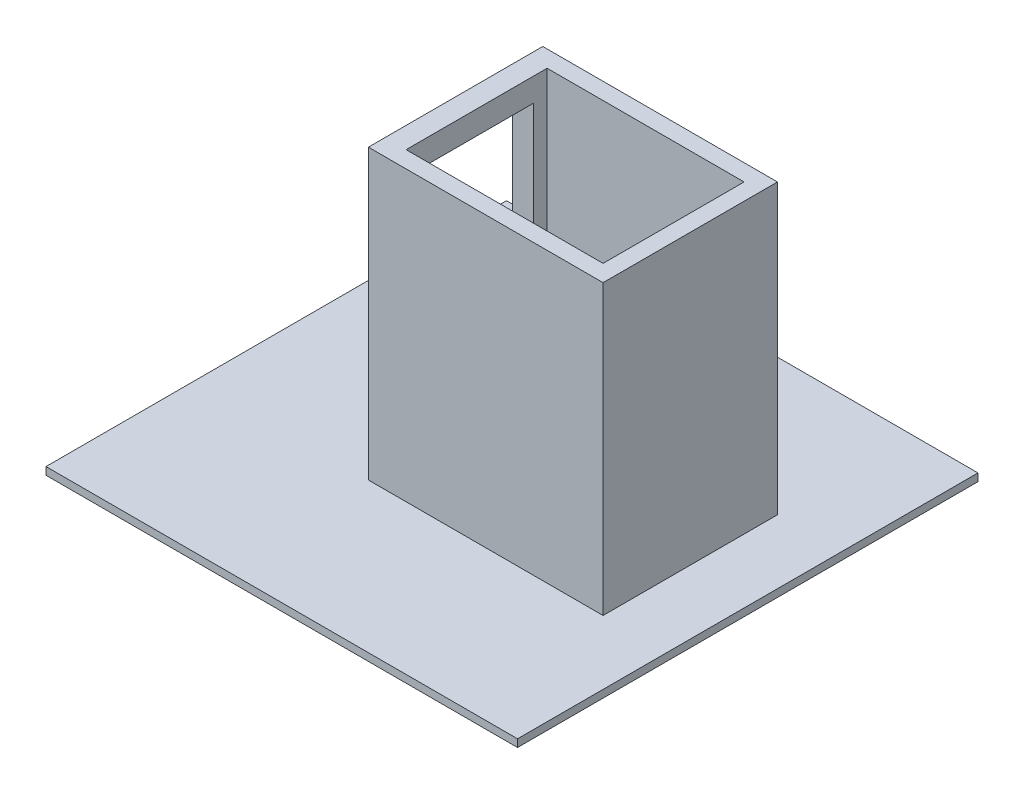
from build123d import *

# Parameters (mm, degrees)
BOSS_EXTRUDE2_DEPTH = 1900
SKETCH6_W           = 717.800772957
SKETCH6_H           = 1750.329682958
CUT_EXTRUDE1_DEPTH  = 1900
SKETCH7_W           = 3107.9102049
SKETCH7_H           = 3035.139999399
BOSS_EXTRUDE3_DEPTH = 50
SKETCH9_W           = 1149.471046449
SKETCH9_H           = 1900
BOSS_EXTRUDE4_DEPTH = 110


with BuildPart() as part:
    # Sketch3 → Boss-Extrude2 (new body)
    with BuildSketch(Plane(origin=(0, 0, 0), x_dir=(1, 0, 0), z_dir=(0, 1, 0))):
        Polygon((0, 0), (1436.838808061, 0), (1436.838808061, -110), (138.623418893, -110), (138.623418893, -1039.471046449), (1436.838808061, -1039.471046449), (1436.838808061, -1149.471046449), (0, -1149.471046449), align=None)
    extrude(amount=BOSS_EXTRUDE2_DEPTH)

    # Sketch6 → Cut-Extrude1 (cut)
    with BuildSketch(Plane.ZY):
        with Locations((558.900386478, 870.222843645)):
            Rectangle(SKETCH6_W, SKETCH6_H)
    extrude(amount=-CUT_EXTRUDE1_DEPTH, mode=Mode.SUBTRACT)

    # Sketch7 → Boss-Extrude3 (add)
    with BuildSketch(Plane(origin=(0, 0, 0), x_dir=(-1, 0, 0), z_dir=(0, -1, 0))):
        with Locations((-414.683163696, -617.583338218)):
            Rectangle(SKETCH7_W, SKETCH7_H)
    extrude(amount=BOSS_EXTRUDE3_DEPTH)

    # Sketch9 → Boss-Extrude4 (add)
    with BuildSketch(Plane(origin=(1436.838808061, 0, 0), x_dir=(0, 0, -1), z_dir=(1, 0, 0))):
        with Locations((-574.735523225, 950)):
            Rectangle(SKETCH9_W, SKETCH9_H)
    extrude(amount=BOSS_EXTRUDE4_DEPTH)


solid = part.part
